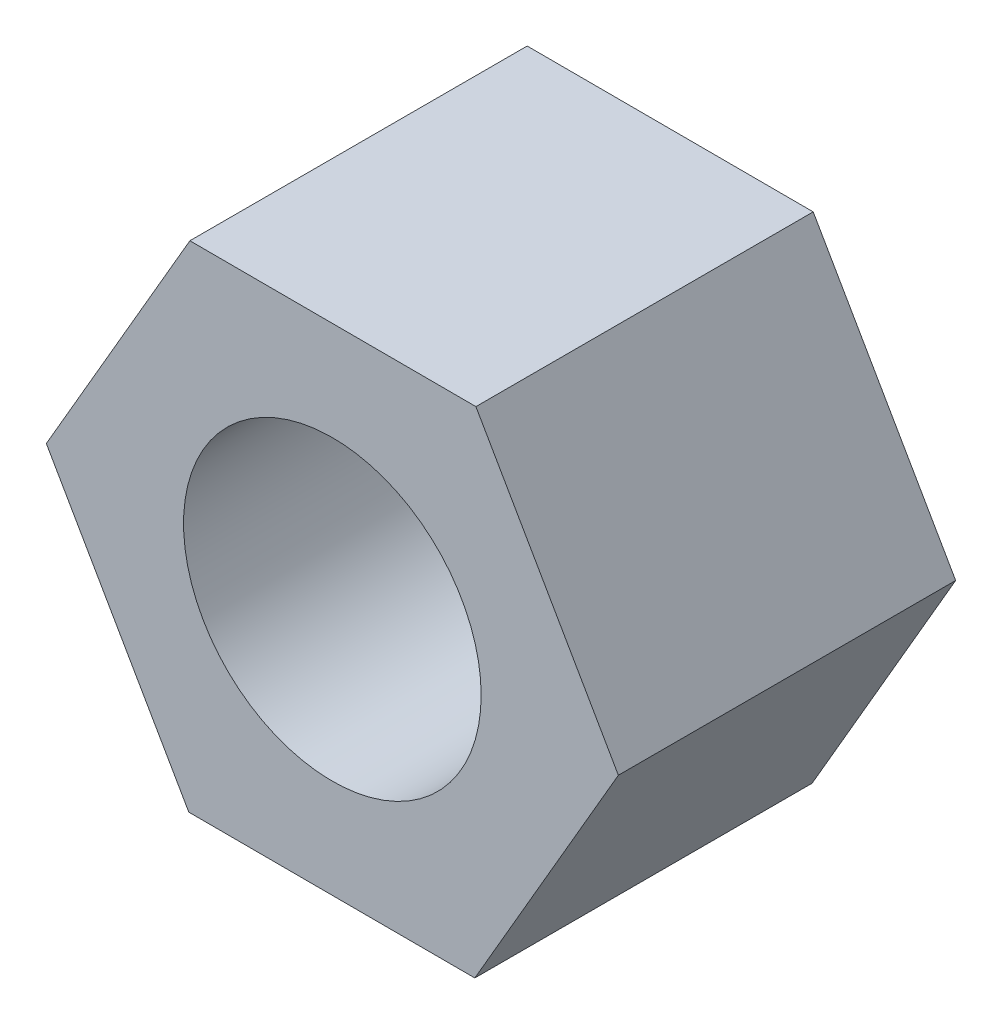
from build123d import *

# Parameters (mm, degrees)
DODANIE_WYCI_GNI_CIE1_DEPTH = 6.8
SZKIC2_R                    = 3
WYTNIJ_WYCI_GNI_CIE1_DEPTH  = 10.8


with BuildPart() as part:
    # Szkic1 → Dodanie-wyciągnięcie1 (new body)
    with BuildSketch(Plane.XY):
        Polygon((-2.87199337, 5), (-5.766123704, 0.012780782), (-2.894130334, -4.987219218), (2.87199337, -5), (5.766123704, -0.012780782), (2.894130334, 4.987219218), align=None)
    extrude(amount=DODANIE_WYCI_GNI_CIE1_DEPTH)

    # Szkic2 → Wytnij-wyciągnięcie1 (cut)
    with BuildSketch(Plane.XY):
        Circle(SZKIC2_R)
    extrude(amount=WYTNIJ_WYCI_GNI_CIE1_DEPTH, mode=Mode.SUBTRACT)


solid = part.part
